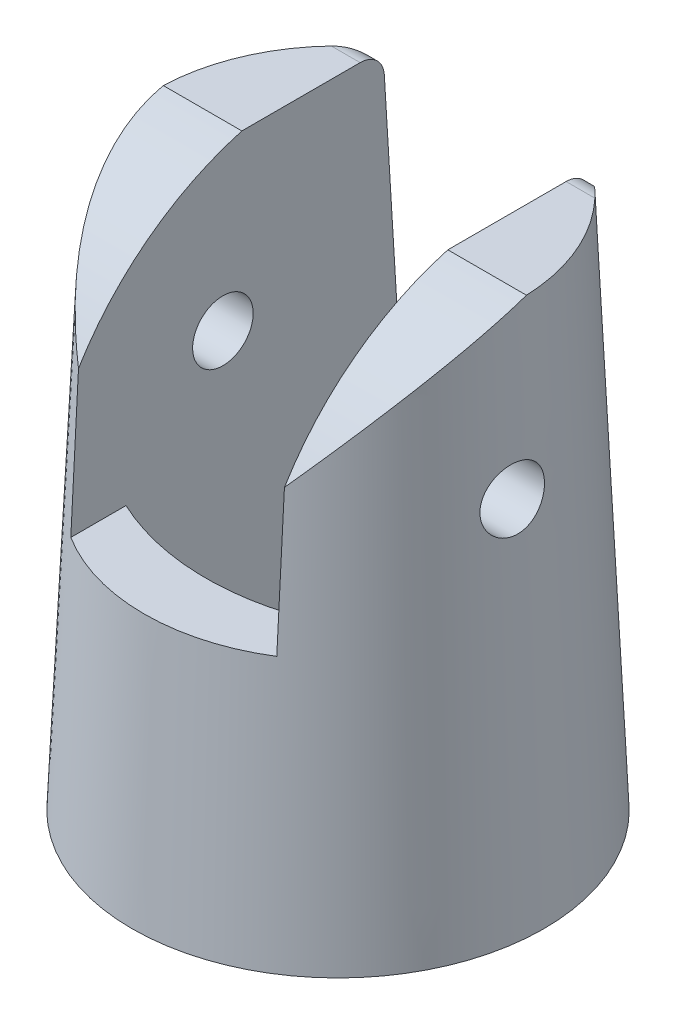
from build123d import *

# Parameters (mm, degrees)
SKETCH2_R               = 7.5
SKETCH3_R               = 8.5
SKETCH9_W               = 8.5
SKETCH9_H               = 24.609106297
CUT_EXTRUDE1_DEPTH      = 10
CUT_EXTRUDE1_DEPTH_BACK = 10
CUT_EXTRUDE2_DEPTH      = 10
CUT_EXTRUDE2_DEPTH_BACK = 10
CUT_EXTRUDE3_DEPTH      = 14
FILLET1_R               = 1
SKETCH12_R              = 1.25
CUT_EXTRUDE4_DEPTH      = 30


with BuildPart() as part:
    # Sketch2 → Loft1 section 0
    with BuildSketch(Plane(origin=(0, 22, 0), x_dir=(1, 0, 0), z_dir=(0, 1, 0))):
        Circle(SKETCH2_R)
    # Sketch3 → Loft1 section 1
    with BuildSketch(Plane(origin=(0, 0, 0), x_dir=(1, 0, 0), z_dir=(0, 1, 0))):
        Circle(SKETCH3_R)
    loft()

    # Sketch9 → Cut-Extrude1 (cut, two sides)
    with BuildSketch(Plane.XY) as cut_extrude1_sk:
        with Locations((0, 23.304553149)):
            Rectangle(SKETCH9_W, SKETCH9_H)
    extrude(amount=CUT_EXTRUDE1_DEPTH, mode=Mode.SUBTRACT)
    extrude(cut_extrude1_sk.sketch, amount=-CUT_EXTRUDE1_DEPTH_BACK, mode=Mode.SUBTRACT)

    # Sketch10 → Cut-Extrude2 (cut, two sides)
    with BuildSketch(Plane(origin=(0, 0, 0), x_dir=(0, 0, -1), z_dir=(1, 0, 0))) as cut_extrude2_sk:
        with BuildLine():
            ThreePointArc((1.551397817, 22.278129211), (-3.230375863, 20.336914385), (-6.681717999, 16.5))
            Line((-6.681717999, 16.5), (-6.777720856, 11))
            Line((-6.777720856, 11), (-14.541953313, 11))
            Line((-14.541953313, 11), (-14.541953313, 25.761445422))
            Line((-14.541953313, 25.761445422), (14.965624753, 25.761445422))
            Line((14.965624753, 25.761445422), (14.965624753, 11))
            Line((14.965624753, 11), (6.777720856, 11))
            Line((6.777720856, 11), (6.043769414, 23))
            Line((6.043769414, 23), (1.551397817, 22.278129211))
        make_face()
    extrude(amount=CUT_EXTRUDE2_DEPTH, mode=Mode.SUBTRACT)
    extrude(cut_extrude2_sk.sketch, amount=-CUT_EXTRUDE2_DEPTH_BACK, mode=Mode.SUBTRACT)

    # Sketch11 → Cut-Extrude3 (cut)
    with BuildSketch(Plane(origin=(0, 0, 0), x_dir=(-1, 0, 0), z_dir=(0, -1, 0))):
        with BuildLine():
            Line((4.25, -4.5), (4.25, 4.5))
            ThreePointArc((4.25, 4.5), (0, 5.448066505), (-4.25, 4.5))
            Line((-4.25, 4.5), (-4.25, -4.5))
            ThreePointArc((-4.25, -4.5), (0, -5.448066505), (4.25, -4.5))
        make_face()
    extrude(amount=-CUT_EXTRUDE3_DEPTH, mode=Mode.SUBTRACT)

    # Fillet1
    fillet1_edges = [part.edges().sort_by_distance(p)[0] for p in [
        (4.303290893, 22, -6.104932034),
        (-4.303290893, 22, -6.104932034),
    ]]
    fillet(fillet1_edges, radius=FILLET1_R)

    # Sketch12 → Cut-Extrude4 (cut, symmetric)
    with BuildSketch(Plane(origin=(0, 0, 0), x_dir=(0, 0, -1), z_dir=(1, 0, 0))):
        with Locations((-0.5, 15.25)):
            Circle(SKETCH12_R)
    extrude(amount=CUT_EXTRUDE4_DEPTH, both=True, mode=Mode.SUBTRACT)


solid = part.part
